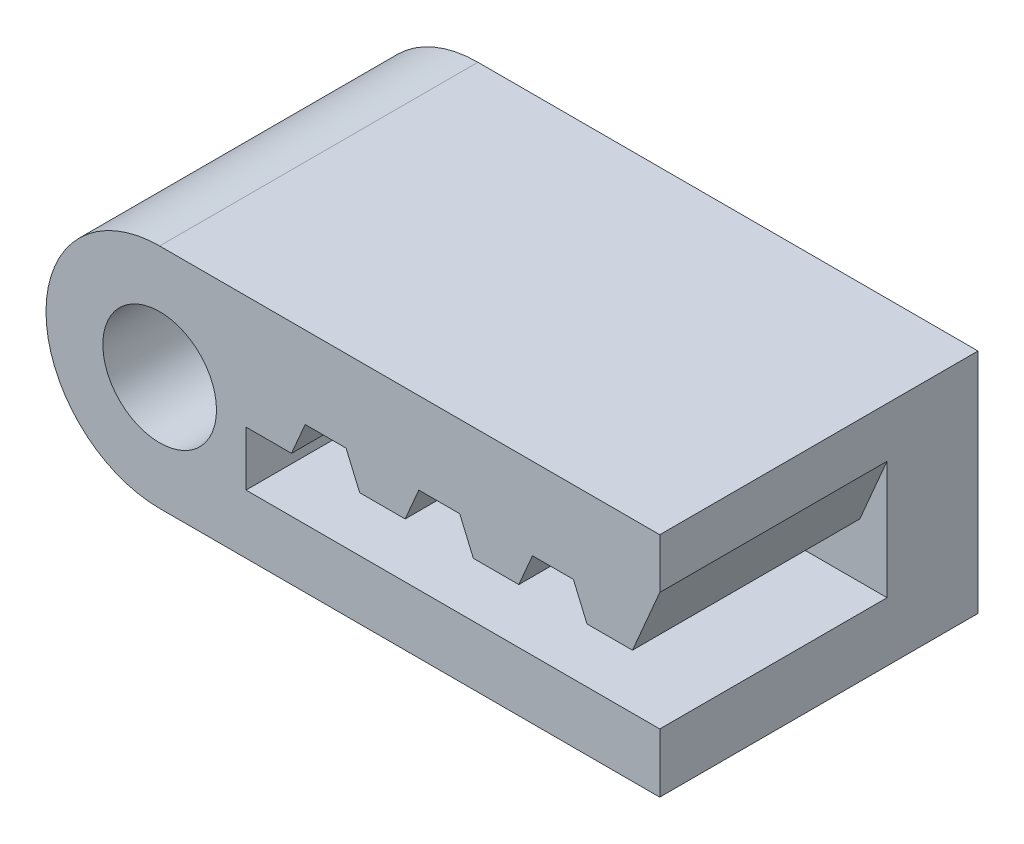
from build123d import *

# Parameters (mm, degrees)
BOSS_EXTRUDE1_DEPTH = 7
CUT_EXTRUDE1_DEPTH  = 5
SKETCH3_R           = 1.25
CUT_EXTRUDE2_DEPTH  = 8


with BuildPart() as part:
    # Sketch1 → Boss-Extrude1 (new body)
    with BuildSketch(Plane.XY):
        with BuildLine():
            Line((0, 0), (11, 0))
            Line((11, 0), (11, 5))
            Line((11, 5), (0, 5))
            ThreePointArc((0, 5), (-2.5, 2.5), (0, 0))
        make_face()
    extrude(amount=BOSS_EXTRUDE1_DEPTH)

    # Sketch2 → Cut-Extrude1 (cut)
    with BuildSketch(Plane.XY.offset(7)):
        Polygon((11, 3.9), (10.4, 2.5), (9.4, 2.5), (9.1, 3.2), (8.2, 3.2), (7.9, 2.5), (6.9, 2.5), (6.6, 3.2), (5.7, 3.2), (5.4, 2.5), (4.4, 2.5), (4.1, 3.2), (3.2, 3.2), (2.9, 2.5), (1.9, 2.5), (1.9, 1.3), (11, 1.3), align=None)
    extrude(amount=-CUT_EXTRUDE1_DEPTH, mode=Mode.SUBTRACT)

    # Sketch3 → Cut-Extrude2 (cut, through all)
    with BuildSketch(Plane.XY.offset(7)):
        with Locations((0, 2.5)):
            Circle(SKETCH3_R)
    extrude(amount=-CUT_EXTRUDE2_DEPTH, mode=Mode.SUBTRACT)


solid = part.part
